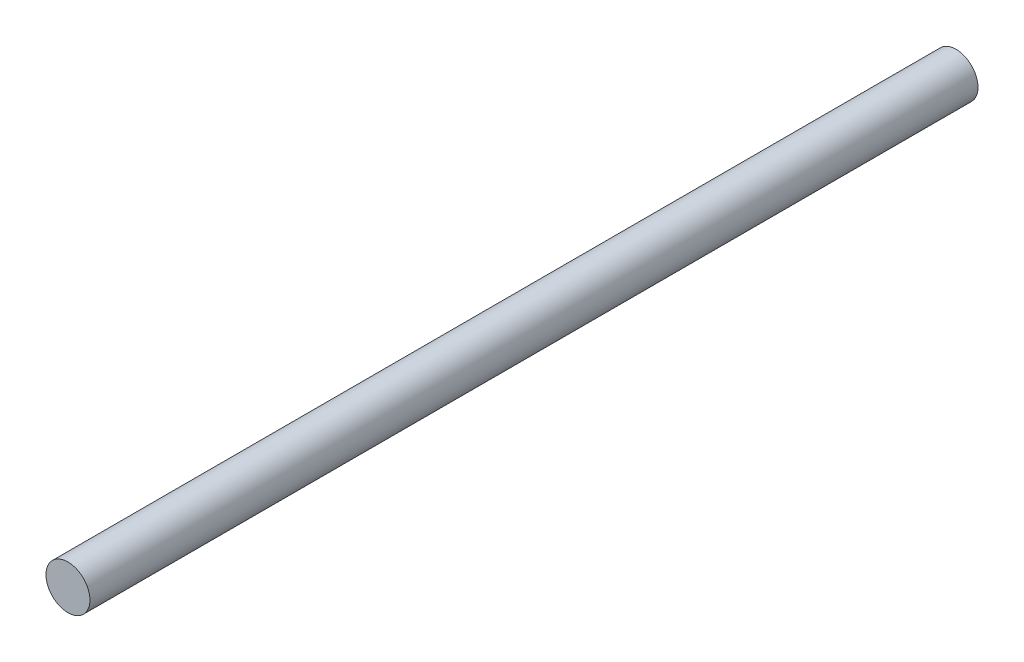
from build123d import *

# Parameters (mm, degrees)
SKETCH1_R           = 25
BOSS_EXTRUDE1_DEPTH = 1010


with BuildPart() as part:
    # Sketch1 → Boss-Extrude1 (new body)
    with BuildSketch(Plane.XY):
        Circle(SKETCH1_R)
    extrude(amount=BOSS_EXTRUDE1_DEPTH)


solid = part.part
